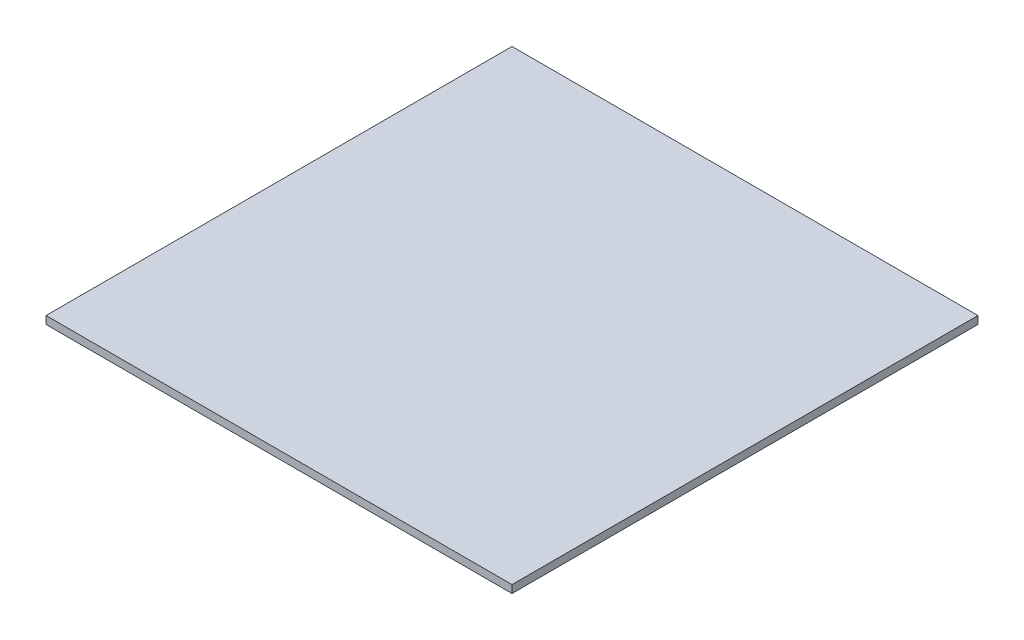
from build123d import *

# Parameters (mm, degrees)
SKETCH1_W           = 1524
SKETCH1_H           = 1524
BOSS_EXTRUDE1_DEPTH = 25.4


with BuildPart() as part:
    # Sketch1 → Boss-Extrude1 (new body)
    with BuildSketch(Plane(origin=(0, 0, 0), x_dir=(1, 0, 0), z_dir=(0, 1, 0))):
        Rectangle(SKETCH1_W, SKETCH1_H)
    extrude(amount=BOSS_EXTRUDE1_DEPTH)


solid = part.part
